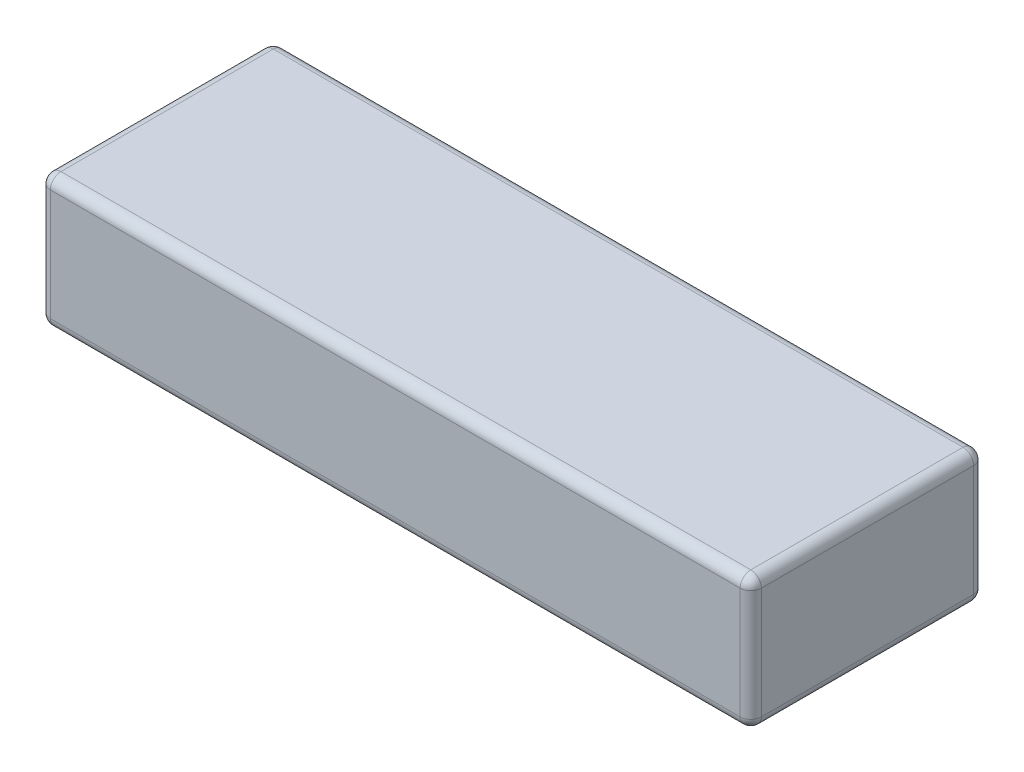
from build123d import *

# Parameters (mm, degrees)
SKETCH1_W           = 134
SKETCH1_H           = 44
BOSS_EXTRUDE1_DEPTH = 25
FILLET1_R           = 2


with BuildPart() as part:
    # Sketch1 → Boss-Extrude1 (new body)
    with BuildSketch(Plane(origin=(0, 0, 0), x_dir=(1, 0, 0), z_dir=(0, 1, 0))):
        Rectangle(SKETCH1_W, SKETCH1_H)
    extrude(amount=BOSS_EXTRUDE1_DEPTH)

    # Fillet1
    fillet1_edges = [part.edges().sort_by_distance(p)[0] for p in [
        (-67, 25, 0),
        (0, 25, 22),
        (67, 25, 0),
        (0, 0, 22),
        (-67, 0, 0),
        (0, 0, -22),
        (67, 0, 0),
        (0, 25, -22),
        (67, 12.5, 22),
        (-67, 12.5, 22),
        (-67, 12.5, -22),
        (67, 12.5, -22),
    ]]
    fillet(fillet1_edges, radius=FILLET1_R)


solid = part.part
